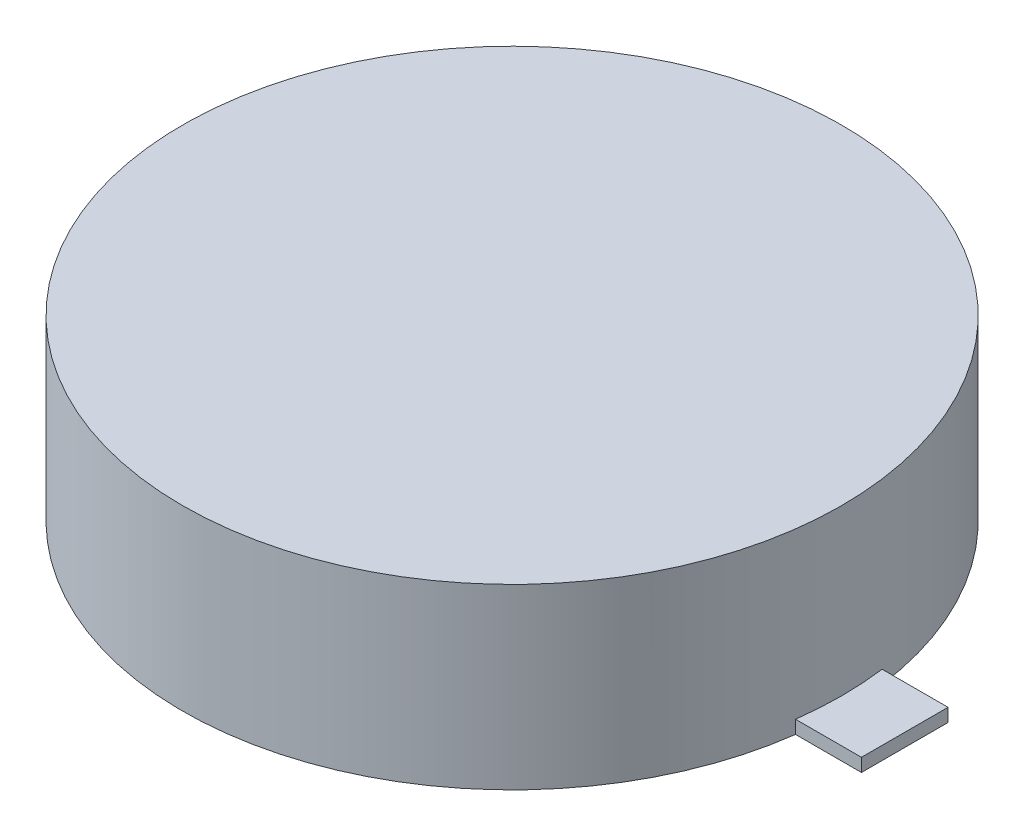
from build123d import *

# Parameters (mm, degrees)
SKETCH1_R           = 5
BOSS_EXTRUDE1_DEPTH = 2.7
SKETCH2_W           = 1
SKETCH2_H           = 1.31363251
BOSS_EXTRUDE2_DEPTH = 0.2


with BuildPart() as part:
    # Sketch1 → Boss-Extrude1 (new body)
    with BuildSketch(Plane(origin=(0, 0, 0), x_dir=(1, 0, 0), z_dir=(0, 1, 0))):
        Circle(SKETCH1_R)
    extrude(amount=BOSS_EXTRUDE1_DEPTH)

    # Sketch2 → Boss-Extrude2 (add)
    with BuildSketch(Plane(origin=(0, 0, 0), x_dir=(1, 0, 0), z_dir=(0, 1, 0))):
        with Locations((5.456671505, 0)):
            Rectangle(SKETCH2_W, SKETCH2_H)
    extrude(amount=BOSS_EXTRUDE2_DEPTH)


solid = part.part
